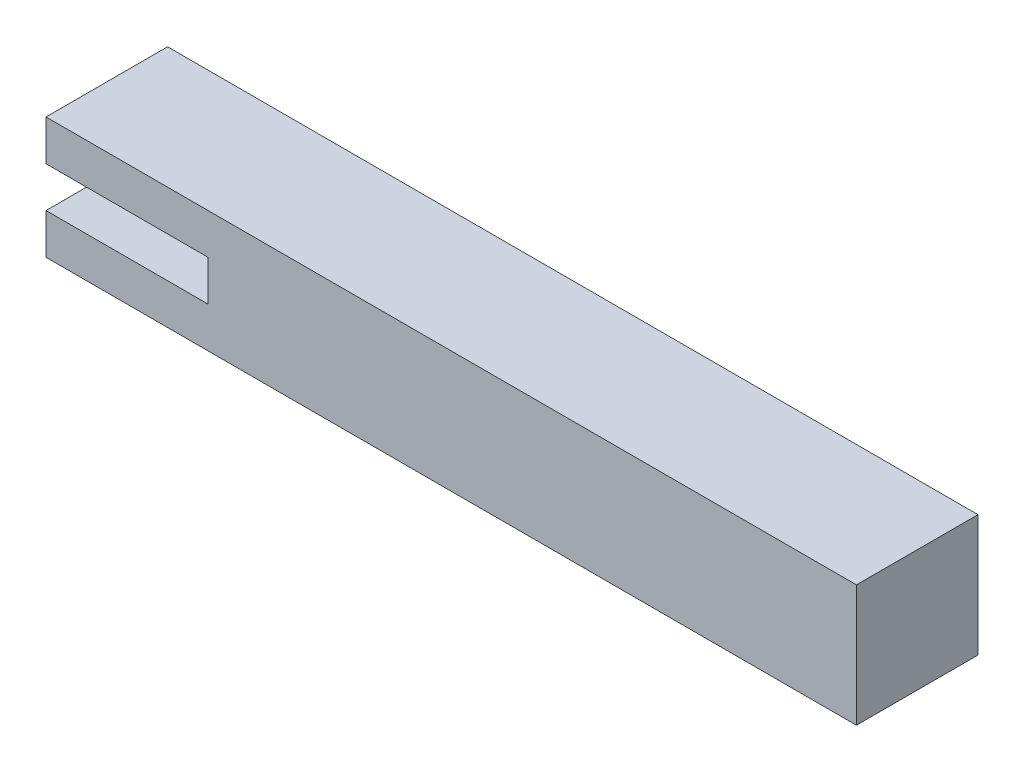
from build123d import *

# Parameters (mm, degrees)
SKETCH2_W           = 30
SKETCH2_H           = 30
BOSS_EXTRUDE1_DEPTH = 200
SKETCH3_W           = 40
SKETCH3_H           = 10
CUT_EXTRUDE1_DEPTH  = 10


with BuildPart() as part:
    # Sketch2 → Boss-Extrude1 (new body)
    with BuildSketch(Plane(origin=(0, 0, 0), x_dir=(0, 0, -1), z_dir=(1, 0, 0))):
        with Locations((15, 15)):
            Rectangle(SKETCH2_W, SKETCH2_H)
    extrude(amount=BOSS_EXTRUDE1_DEPTH)

    # Sketch3 → Cut-Extrude1 (cut)
    with BuildSketch(Plane.XY):
        with Locations((20, 15)):
            Rectangle(SKETCH3_W, SKETCH3_H)
    extrude(amount=-CUT_EXTRUDE1_DEPTH, mode=Mode.SUBTRACT)


solid = part.part
